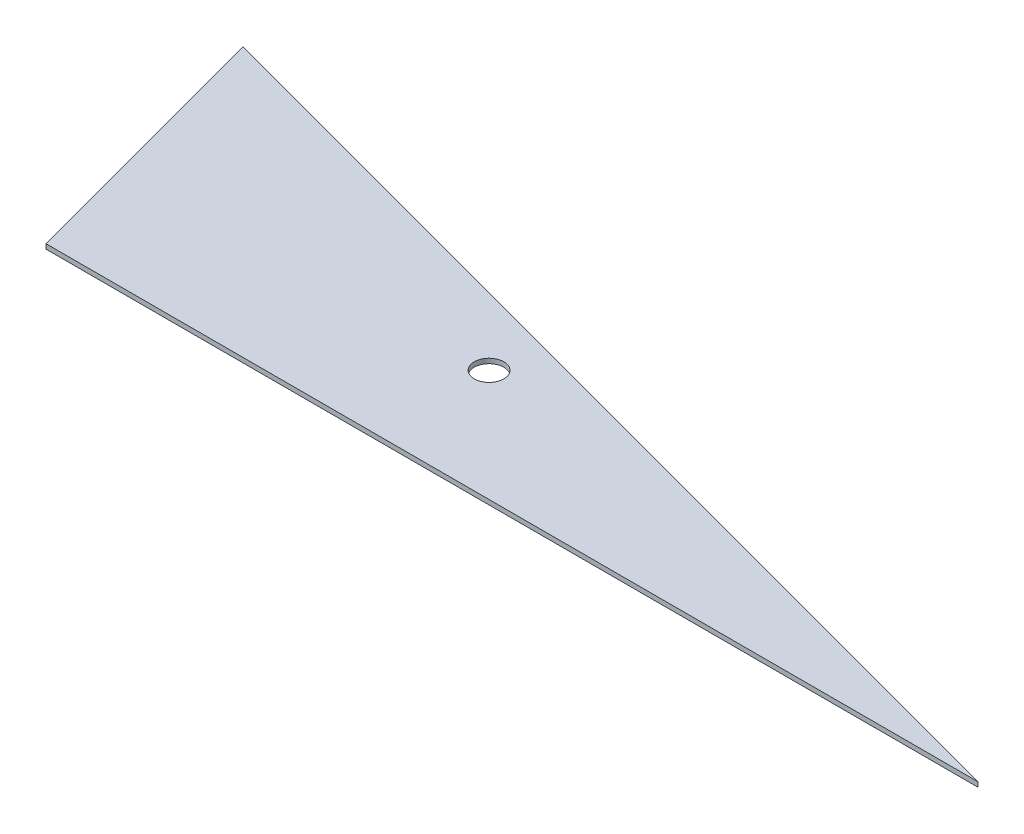
from build123d import *

# Parameters (mm, degrees)
BOSS_EXTRUDE1_DEPTH = 2.54
SKETCH2_R           = 7.9375
CUT_EXTRUDE1_DEPTH  = 2.54
CUT_EXTRUDE2_DEPTH  = 2.54


with BuildPart() as part:
    # Sketch1 → Boss-Extrude1 (new body)
    with BuildSketch(Plane(origin=(0, 0, 0), x_dir=(1, 0, 0), z_dir=(0, 1, 0))):
        Polygon((-288.635862607, -221.384099055), (-288.635862607, -365.420521122), (248.915382685, -365.420521122), align=None)
    extrude(amount=BOSS_EXTRUDE1_DEPTH)

    # Sketch2 → Cut-Extrude1 (cut)
    with BuildSketch(Plane(origin=(0, 2.54, 0), x_dir=(1, 0, 0), z_dir=(0, 1, 0))):
        with Locations((-72.735862607, -305.530344684)):
            Circle(SKETCH2_R)
    extrude(amount=-CUT_EXTRUDE1_DEPTH, mode=Mode.SUBTRACT)

    # Sketch3 → Cut-Extrude2 (cut)
    with BuildSketch(Plane.XZ):
        Polygon((-288.635862607, 221.384099055), (-250.041419634, 365.420521122), (-288.635862607, 365.420521122), align=None)
    extrude(amount=-CUT_EXTRUDE2_DEPTH, mode=Mode.SUBTRACT)


solid = part.part
